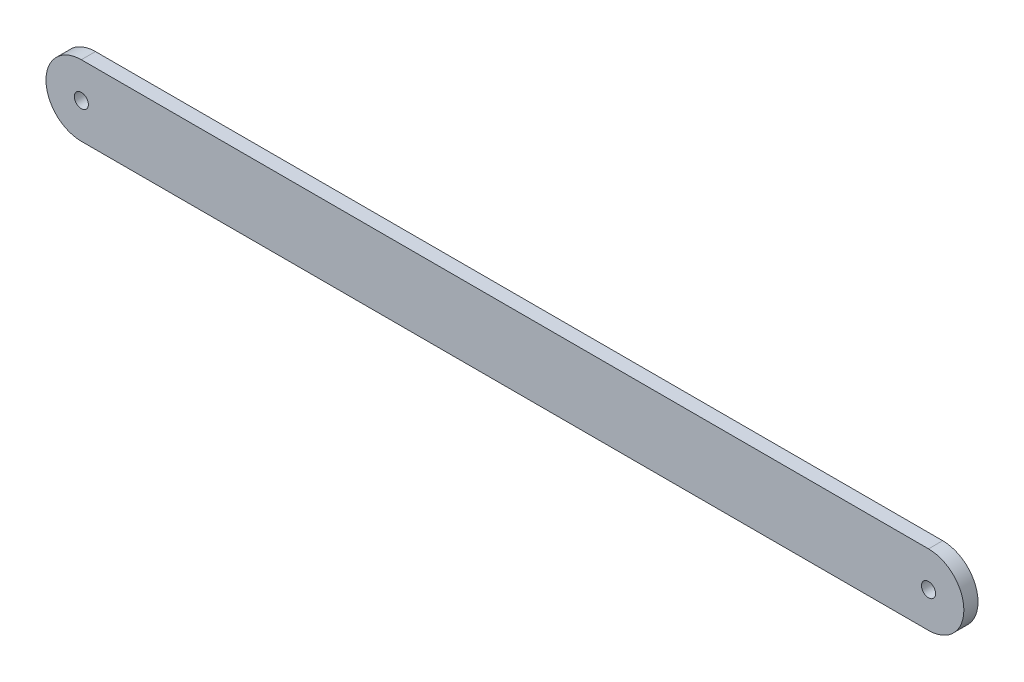
from build123d import *

# Parameters (mm, degrees)
SKETCH_1_R      = 2
EXTRUDE_1_DEPTH = 4


with BuildPart() as part:
    # 草图1 → 凸台-拉伸1 (new body)
    with BuildSketch(Plane.XY):
        with BuildLine():
            Line((119.76, -10), (-120, -10))
            ThreePointArc((-120, -10), (-130, 0), (-120, 10))
            Line((-120, 10), (119.76, 10))
            ThreePointArc((119.76, 10), (129.76, 0), (119.76, -10))
        make_face()
        with Locations((-120, 0)):
            Circle(SKETCH_1_R, mode=Mode.SUBTRACT)
        with Locations((119.76, 0)):
            Circle(SKETCH_1_R, mode=Mode.SUBTRACT)
    extrude(amount=EXTRUDE_1_DEPTH)


solid = part.part
